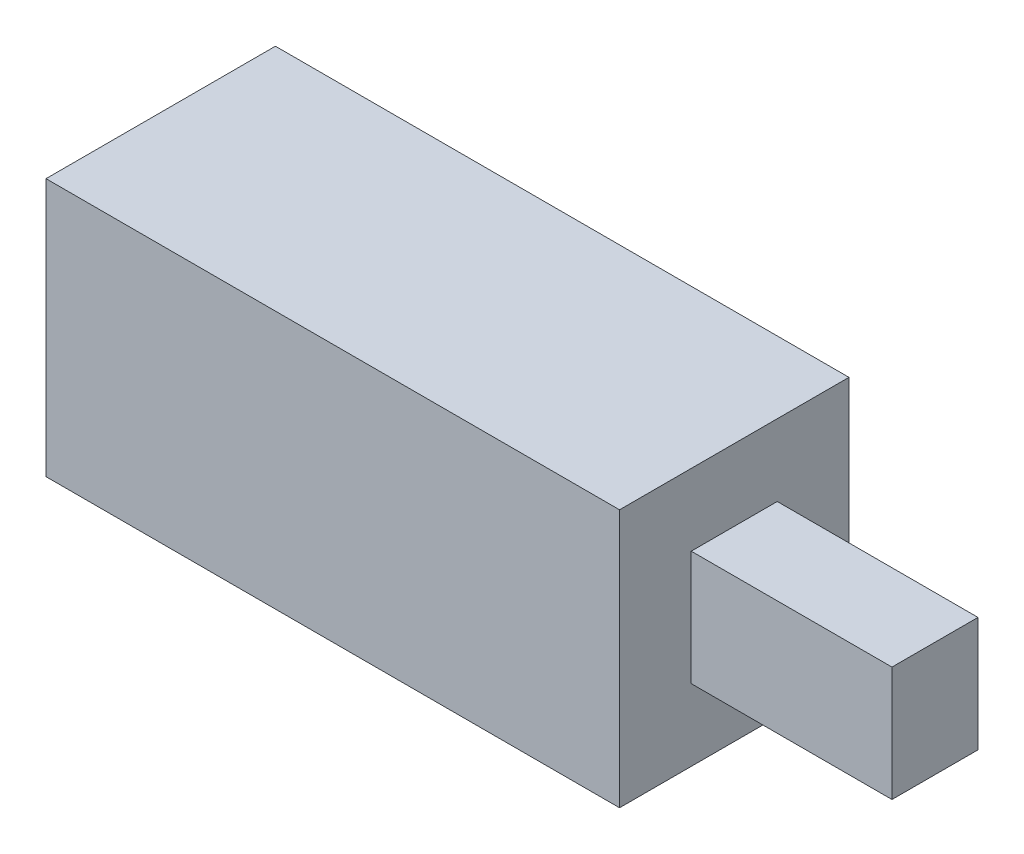
from build123d import *

# Parameters (mm, degrees)
SKETCH2_W           = 20
SKETCH2_H           = 9
BOSS_EXTRUDE1_DEPTH = 8
SKETCH3_W           = 4
SKETCH3_H           = 5
CUT_EXTRUDE1_DEPTH  = 10
SKETCH4_W           = 3
SKETCH4_H           = 4
BOSS_EXTRUDE2_DEPTH = 7


with BuildPart() as part:
    # Sketch2 → Boss-Extrude1 (new body)
    with BuildSketch(Plane.XY):
        Rectangle(SKETCH2_W, SKETCH2_H)
    extrude(amount=BOSS_EXTRUDE1_DEPTH)

    # Sketch3 → Cut-Extrude1 (cut)
    with BuildSketch(Plane.ZY.offset(10)):
        with Locations((4, 0)):
            Rectangle(SKETCH3_W, SKETCH3_H)
    extrude(amount=-CUT_EXTRUDE1_DEPTH, mode=Mode.SUBTRACT)

    # Sketch4 → Boss-Extrude2 (add)
    with BuildSketch(Plane(origin=(10, 0, 0), x_dir=(0, 0, -1), z_dir=(1, 0, 0))):
        with Locations((-4, 0)):
            Rectangle(SKETCH4_W, SKETCH4_H)
    extrude(amount=BOSS_EXTRUDE2_DEPTH)


solid = part.part
